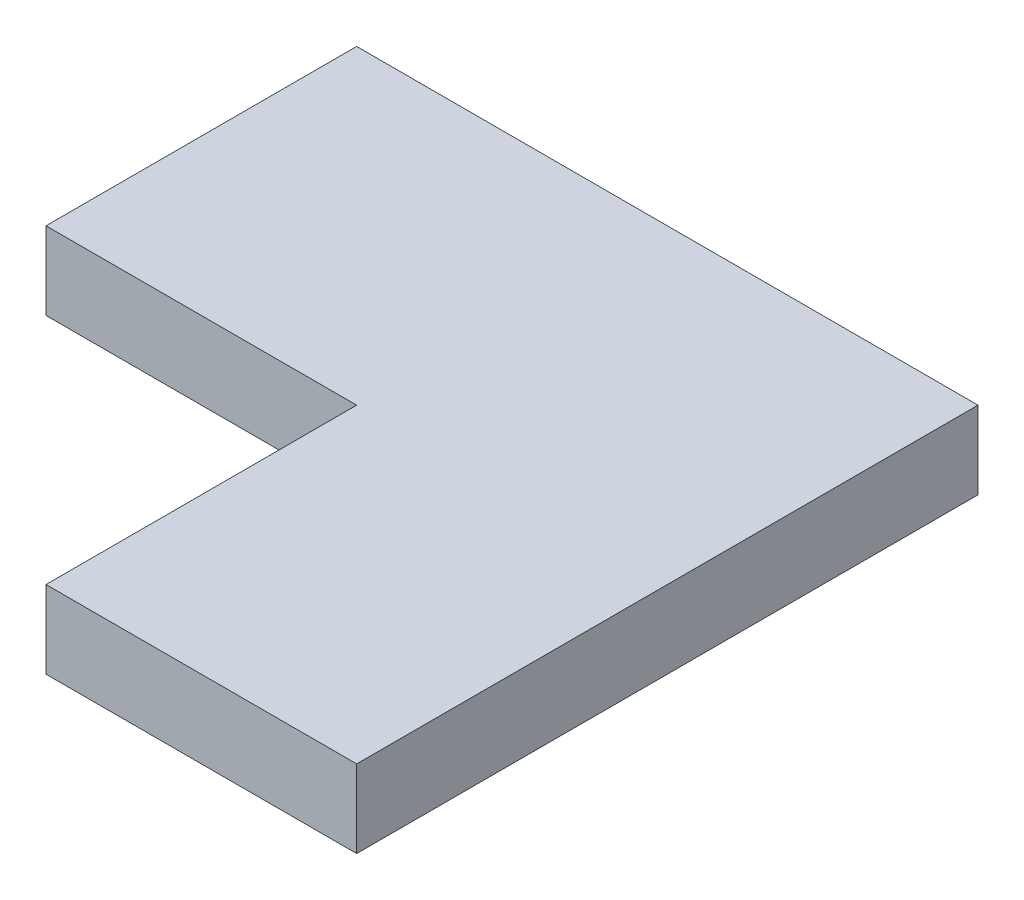
from build123d import *

# Parameters (mm, degrees)
SKETCH1_W           = 100
SKETCH1_H           = 100
SKETCH1_W_2         = 200
BOSS_EXTRUDE1_DEPTH = 25


with BuildPart() as part:
    # Sketch1 → Boss-Extrude1 (new body)
    with BuildSketch(Plane(origin=(0, 0, 0), x_dir=(1, 0, 0), z_dir=(0, 1, 0))):
        with Locations((50, -100)):
            Rectangle(SKETCH1_W, SKETCH1_H)
        Rectangle(SKETCH1_W_2, SKETCH1_H)
    extrude(amount=BOSS_EXTRUDE1_DEPTH)


solid = part.part
